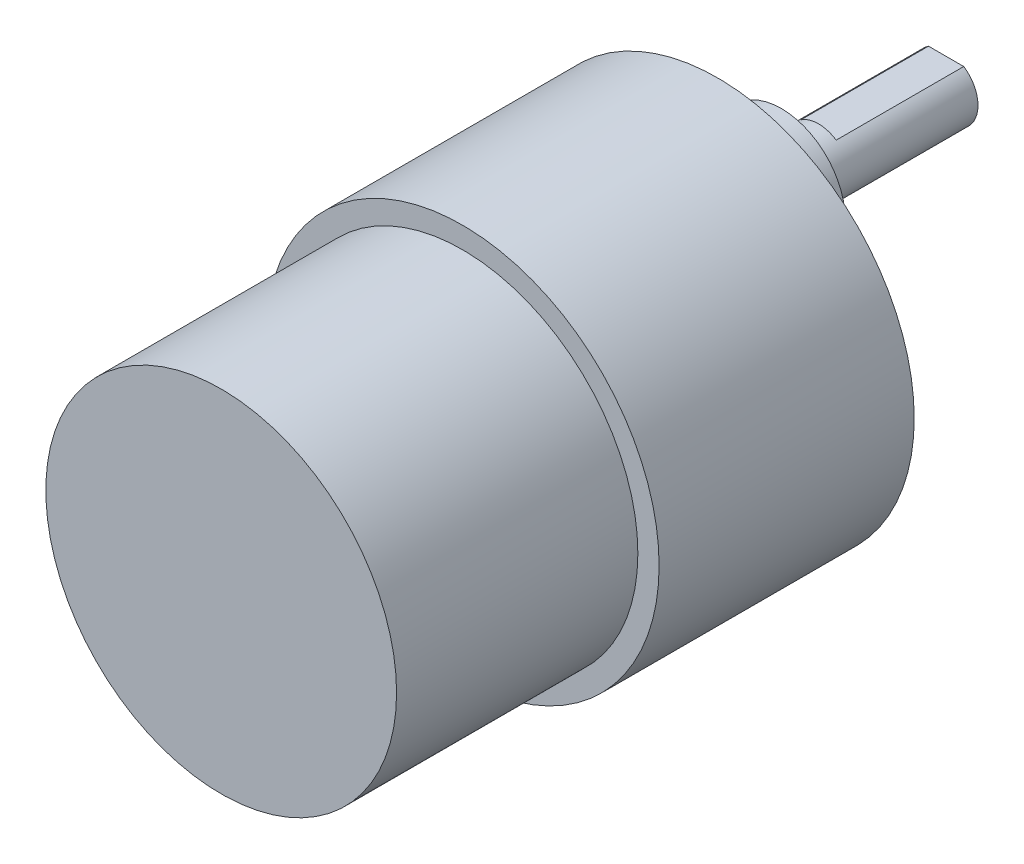
from build123d import *

# Parameters (mm, degrees)
SKETCH_1_R             = 18.5
EXTRUDE_1_DEPTH        = 24
SKETCH_2_R             = 16.5
EXTRUDE_2_DEPTH        = 22.7
SKETCH_3_R             = 6
EXTRUDE_3_DEPTH        = 6
SKETCH_4_R             = 3
EXTRUDE_4_DEPTH        = 15.5
SKETCH_5_W             = 5.944067487
SKETCH_5_H             = 2.922499848
CUT_EXTRUDE_1_DEPTH    = 12
HOLE_WIZARD_M3_1_D     = 2.5
HOLE_WIZARD_M3_1_DEPTH = 7.5
HOLE_WIZARD_M3_1_TIP   = 0.751075774


with BuildPart() as part:
    # 草图1 → 凸台-拉伸1 (new body)
    with BuildSketch(Plane.XY):
        Circle(SKETCH_1_R)
    extrude(amount=EXTRUDE_1_DEPTH)

    # 草图2 → 凸台-拉伸2 (add)
    with BuildSketch(Plane.XY.offset(24)):
        Circle(SKETCH_2_R)
    extrude(amount=EXTRUDE_2_DEPTH)

    # 草图3 → 凸台-拉伸3 (add)
    with BuildSketch(Plane(origin=(0, 0, 0), x_dir=(-1, 0, 0), z_dir=(0, 0, -1))):
        with Locations((0, 7)):
            Circle(SKETCH_3_R)
    extrude(amount=EXTRUDE_3_DEPTH)

    # 草图4 → 凸台-拉伸4 (add)
    with BuildSketch(Plane(origin=(0, 0, -6), x_dir=(-1, 0, 0), z_dir=(0, 0, -1))):
        with Locations((0, 7)):
            Circle(SKETCH_4_R)
    extrude(amount=EXTRUDE_4_DEPTH)

    # 草图5 → 切除-拉伸1 (cut)
    with BuildSketch(Plane(origin=(0, 0, -21.5), x_dir=(-1, 0, 0), z_dir=(0, 0, -1))):
        with Locations((0.222902531, 10.961249924)):
            Rectangle(SKETCH_5_W, SKETCH_5_H)
    extrude(amount=-CUT_EXTRUDE_1_DEPTH, mode=Mode.SUBTRACT)

    # M3 螺纹孔1
    with Locations(Plane(origin=(0, 0, 0), x_dir=(-1, 0, 0), z_dir=(0, 0, -1))):
        with Locations((-15.5, 0), (-7.75, 13.423393759), (7.75, 13.423393759), (15.5, 0), (7.75, -13.423393759), (-7.75, -13.423393759)):
            Hole(HOLE_WIZARD_M3_1_D / 2, depth=HOLE_WIZARD_M3_1_DEPTH)
            with Locations((0, 0, -(HOLE_WIZARD_M3_1_DEPTH + HOLE_WIZARD_M3_1_TIP / 2))):  # 118° drill point
                Cone(0, HOLE_WIZARD_M3_1_D / 2, HOLE_WIZARD_M3_1_TIP, mode=Mode.SUBTRACT)


solid = part.part
